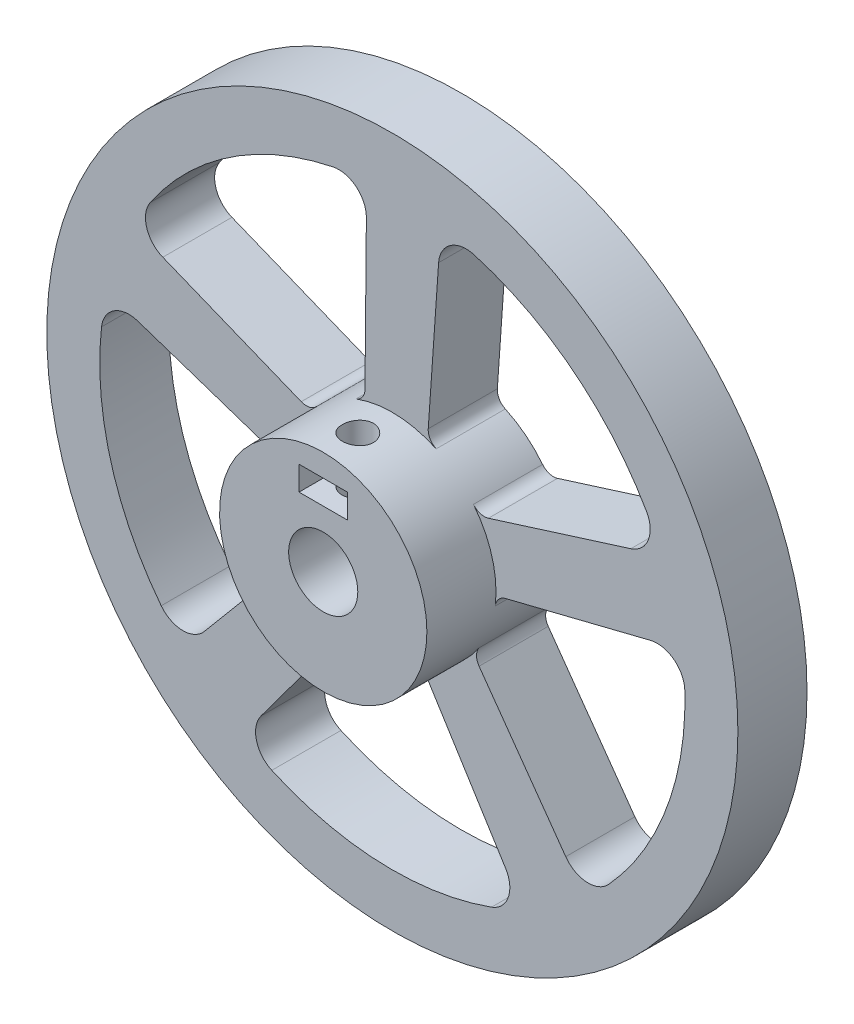
from build123d import *

# Parameters (mm, degrees)
ESQUISSE1_R              = 15
ESQUISSE1_R_2            = 5
BOSS_EXTRU_4_DEPTH       = 10
ESQUISSE3_R              = 50
BOSS_EXTRU_5_DEPTH       = 10
ESQUISSE14_R             = 5
ENL_V_MAT_EXTRU_1_DEPTH  = 10
ENL_V_MAT_EXTRU_7_DEPTH  = 10
ENL_V_MAT_EXTRU_8_REACH  = 52
ESQUISSE20_R             = 2.25
ESQUISSE25_W             = 7
ESQUISSE25_H             = 3.5
ENL_V_MAT_EXTRU_10_DEPTH = 10


with BuildPart() as part:
    # Esquisse1 → Boss.-Extru.4 (new body)
    with BuildSketch(Plane.XY):
        Circle(ESQUISSE1_R)
        Circle(ESQUISSE1_R_2, mode=Mode.SUBTRACT)
    extrude(amount=BOSS_EXTRU_4_DEPTH)

    # Esquisse3 → Boss.-Extru.5 (add)
    with BuildSketch(Plane.XY):
        Circle(ESQUISSE3_R)
    extrude(amount=-BOSS_EXTRU_5_DEPTH)

    # Esquisse14 → Enlèv. mat.-Extru.1 (cut)
    with BuildSketch(Plane.XY):
        Circle(ESQUISSE14_R)
    extrude(amount=-ENL_V_MAT_EXTRU_1_DEPTH, mode=Mode.SUBTRACT)

    # Esquisse19 → Enlèv. mat.-Extru.7 (cut)
    with BuildSketch(Plane.XY):
        with BuildLine():
            Line((-13.338573188, -9.521928054), (-27.218975217, -26.077663465))
            ThreePointArc((-27.218975217, -26.077663465), (-30.359478039, -27.507055347), (-33.443966468, -25.96049456))
            ThreePointArc((-33.443966468, -25.96049456), (-40.74820108, -11.49044297), (-42.079621744, 4.663861575))
            ThreePointArc((-42.079621744, 4.663861575), (-40.257507229, 7.594018196), (-36.832899826, 8.015898828))
            Line((-36.832899826, 8.015898828), (-16.348106085, 1.150685003))
            ThreePointArc((-16.348106085, 1.150685003), (-15.386221176, 0.457781948), (-14.985564031, -0.65792907))
            ThreePointArc((-14.985564031, -0.65792907), (-14.436989432, -4.07103625), (-13.121635222, -7.267921925))
            ThreePointArc((-13.121635222, -7.267921925), (-12.88038592, -8.428583804), (-13.338573188, -9.521928054))
        make_face()
        with BuildLine():
            Line((-13.177737519, 9.74329936), (-33.212457679, 17.828342562))
            ThreePointArc((-33.212457679, 17.828342562), (-35.542358886, 20.373431853), (-35.024651516, 23.784868238))
            ThreePointArc((-35.024651516, 23.784868238), (-23.519947285, 35.203100014), (-8.567722294, 41.461310949))
            ThreePointArc((-8.567722294, 41.461310949), (-5.217913395, 40.633845258), (-3.758419184, 37.507218357))
            Line((-3.758419184, 37.507218357), (-3.957476136, 15.903554042))
            ThreePointArc((-3.957476136, 15.903554042), (-4.319227318, 14.774628312), (-5.256521685, 14.048807059))
            ThreePointArc((-5.256521685, 14.048807059), (-8.333060636, 12.472373489), (-10.967012784, 10.233505294))
            ThreePointArc((-10.967012784, 10.233505294), (-11.996317693, 9.645399328), (-13.177737519, 9.74329936))
        make_face()
        with BuildLine():
            Line((5.194283506, 15.543618221), (6.692547521, 37.096185131))
            ThreePointArc((6.692547521, 37.096185131), (8.393092207, 40.098528699), (11.797541387, 40.660351549))
            ThreePointArc((11.797541387, 40.660351549), (26.212074244, 33.247155288), (36.78447816, 20.96063781))
            ThreePointArc((36.78447816, 20.96063781), (37.032659401, 17.519079267), (34.510069026, 15.16483694))
            Line((34.510069026, 15.16483694), (13.902251323, 8.678251937))
            ThreePointArc((13.902251323, 8.678251937), (12.716791888, 8.67344052), (11.736854967, 9.340569333))
            ThreePointArc((11.736854967, 9.340569333), (9.286874729, 11.779386986), (6.343648566, 13.59257602))
            ThreePointArc((6.343648566, 13.59257602), (5.466253846, 14.389768423), (5.194283506, 15.543618221))
        make_face()
        with BuildLine():
            Line((-19.005564812, -32.553120431), (-6.146209076, -15.1923916))
            ThreePointArc((-6.146209076, -15.1923916), (-5.189980327, -14.491703509), (-4.005066227, -14.455429586))
            ThreePointArc((-4.005066227, -14.455429586), (-0.589489528, -14.988412261), (2.857396229, -14.725328071))
            ThreePointArc((2.857396229, -14.725328071), (4.035801406, -14.854550596), (4.934045928, -15.628174536))
            Line((4.934045928, -15.628174536), (16.390205856, -33.945224931))
            ThreePointArc((16.390205856, -33.945224931), (16.779169577, -37.373726988), (14.35514352, -39.829336241))
            ThreePointArc((14.35514352, -39.829336241), (-1.663825962, -42.304584315), (-17.438914178, -38.578885977))
            ThreePointArc((-17.438914178, -38.578885977), (-19.662594375, -35.940483902), (-19.005564812, -32.553120431))
        make_face()
        with BuildLine():
            Line((16.387981273, -0.136814991), (37.348679518, 5.098360702))
            ThreePointArc((37.348679518, 5.098360702), (40.729575141, 4.408821782), (42.315933076, 1.344611014))
            ThreePointArc((42.315933076, 1.344611014), (39.719900084, -14.655228017), (31.301780055, -28.506924356))
            ThreePointArc((31.301780055, -28.506924356), (28.105355598, -29.80645882), (25.086814797, -28.134833694))
            Line((25.086814797, -28.134833694), (12.549539974, -10.540099382))
            ThreePointArc((12.549539974, -10.540099382), (12.178636933, -9.414147271), (12.510296976, -8.276017736))
            ThreePointArc((12.510296976, -8.276017736), (14.072664867, -5.192311964), (14.887603211, -1.832831318))
            ThreePointArc((14.887603211, -1.832831318), (15.374648361, -0.752033352), (16.387981273, -0.136814991))
        make_face()
    extrude(amount=-ENL_V_MAT_EXTRU_7_DEPTH, mode=Mode.SUBTRACT)

    # Esquisse20 → Enlèv. mat.-Extru.8 (cut, up to next)
    with BuildSketch(Plane(origin=(0, 0, 0), x_dir=(1, 0, 0), z_dir=(0, 1, 0)), mode=Mode.PRIVATE) as enl_v_mat_extru_8_sk1:
        with Locations((0, -5)):
            Circle(ESQUISSE20_R)
    enl_v_mat_extru_8_tool1 = extrude(enl_v_mat_extru_8_sk1.sketch, amount=ENL_V_MAT_EXTRU_8_REACH, mode=Mode.PRIVATE) & part.part
    add(enl_v_mat_extru_8_tool1.solids().sort_by_distance((0, 0, 5))[0], mode=Mode.SUBTRACT)

    # Esquisse25 → Enlèv. mat.-Extru.10 (cut)
    with BuildSketch(Plane.XY):
        with Locations((0, 10)):
            Rectangle(ESQUISSE25_W, ESQUISSE25_H)
    extrude(amount=ENL_V_MAT_EXTRU_10_DEPTH, mode=Mode.SUBTRACT)


solid = part.part
